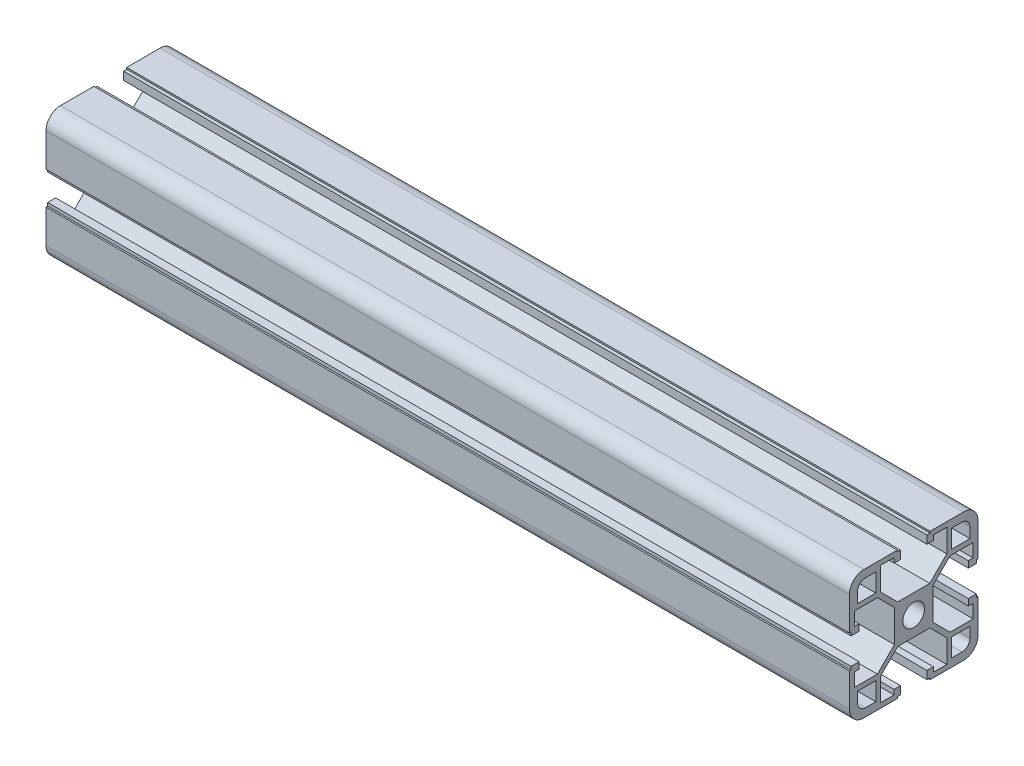
from build123d import *

# Parameters (mm, degrees)
SKETCH1_R                 = 3.4
F_40_X_40L_X_R4_5_1_DEPTH = 250


with BuildPart() as part:
    # Sketch1 → 铝型材 40 X 40L X R4.5(1) (new body)
    with BuildSketch(Plane(origin=(-142.412451362, 0, 0), x_dir=(0, 0, -1), z_dir=(1, 0, 0))):
        with BuildLine():
            Line((-5.1, 20), (-5.1, 19.5))
            Line((-5.1, 19.5), (-4.1, 19.5))
            Line((-4.1, 19.5), (-4.1, 17))
            Line((-4.1, 17), (-6.1, 17))
            Line((-6.1, 17), (-6.1, 18.5))
            Line((-6.1, 18.5), (-10.3, 18.5))
            Line((-10.3, 18.5), (-10.3, 11.3))
            Line((-10.3, 11.3), (-5, 6))
            Line((-5, 6), (5, 6))
            Line((5, 6), (10.3, 11.3))
            Line((10.3, 11.3), (10.3, 18.5))
            Line((10.3, 18.5), (6.1, 18.5))
            Line((6.1, 18.5), (6.1, 17))
            Line((6.1, 17), (4.1, 17))
            Line((4.1, 17), (4.1, 19.5))
            Line((4.1, 19.5), (5.1, 19.5))
            Line((5.1, 19.5), (5.1, 20))
            Line((5.1, 20), (15.5, 20))
            ThreePointArc((15.5, 20), (18.681980515, 18.681980515), (20, 15.5))
            Line((20, 15.5), (20, 5.1))
            Line((20, 5.1), (19.5, 5.1))
            Line((19.5, 5.1), (19.5, 4.1))
            Line((19.5, 4.1), (17, 4.1))
            Line((17, 4.1), (17, 6.1))
            Line((17, 6.1), (18.5, 6.1))
            Line((18.5, 6.1), (18.5, 10.3))
            Line((18.5, 10.3), (11.3, 10.3))
            Line((11.3, 10.3), (6, 5))
            Line((6, 5), (6, -5))
            Line((6, -5), (11.3, -10.3))
            Line((11.3, -10.3), (18.5, -10.3))
            Line((18.5, -10.3), (18.5, -6.1))
            Line((18.5, -6.1), (17, -6.1))
            Line((17, -6.1), (17, -4.1))
            Line((17, -4.1), (19.5, -4.1))
            Line((19.5, -4.1), (19.5, -5.1))
            Line((19.5, -5.1), (20, -5.1))
            Line((20, -5.1), (20, -15.5))
            ThreePointArc((20, -15.5), (18.681980515, -18.681980515), (15.5, -20))
            Line((15.5, -20), (5.1, -20))
            Line((5.1, -20), (5.1, -19.5))
            Line((5.1, -19.5), (4.1, -19.5))
            Line((4.1, -19.5), (4.1, -17))
            Line((4.1, -17), (6.1, -17))
            Line((6.1, -17), (6.1, -18.5))
            Line((6.1, -18.5), (10.3, -18.5))
            Line((10.3, -18.5), (10.3, -11.3))
            Line((10.3, -11.3), (5, -6))
            Line((5, -6), (-5, -6))
            Line((-5, -6), (-10.3, -11.3))
            Line((-10.3, -11.3), (-10.3, -18.5))
            Line((-10.3, -18.5), (-6.1, -18.5))
            Line((-6.1, -18.5), (-6.1, -17))
            Line((-6.1, -17), (-4.1, -17))
            Line((-4.1, -17), (-4.1, -19.5))
            Line((-4.1, -19.5), (-5.1, -19.5))
            Line((-5.1, -19.5), (-5.1, -20))
            Line((-5.1, -20), (-15.5, -20))
            ThreePointArc((-15.5, -20), (-18.681980515, -18.681980515), (-20, -15.5))
            Line((-20, -15.5), (-20, -5.1))
            Line((-20, -5.1), (-19.5, -5.1))
            Line((-19.5, -5.1), (-19.5, -4.1))
            Line((-19.5, -4.1), (-17, -4.1))
            Line((-17, -4.1), (-17, -6.1))
            Line((-17, -6.1), (-18.5, -6.1))
            Line((-18.5, -6.1), (-18.5, -10.3))
            Line((-18.5, -10.3), (-11.3, -10.3))
            Line((-11.3, -10.3), (-6, -5))
            Line((-6, -5), (-6, 5))
            Line((-6, 5), (-11.3, 10.3))
            Line((-11.3, 10.3), (-18.5, 10.3))
            Line((-18.5, 10.3), (-18.5, 6.1))
            Line((-18.5, 6.1), (-17, 6.1))
            Line((-17, 6.1), (-17, 4.1))
            Line((-17, 4.1), (-19.5, 4.1))
            Line((-19.5, 4.1), (-19.5, 5.1))
            Line((-19.5, 5.1), (-20, 5.1))
            Line((-20, 5.1), (-20, 15.5))
            ThreePointArc((-20, 15.5), (-18.681980515, 18.681980515), (-15.5, 20))
            Line((-15.5, 20), (-5.1, 20))
        make_face()
        Circle(SKETCH1_R, mode=Mode.SUBTRACT)
        with BuildLine():
            Line((11.8, 17.5), (15, 17.5))
            ThreePointArc((15, 17.5), (16.767766953, 16.767766953), (17.5, 15))
            Line((17.5, 15), (17.5, 11.8))
            Line((17.5, 11.8), (11.8, 11.8))
            Line((11.8, 11.8), (11.8, 17.5))
        make_face(mode=Mode.SUBTRACT)
        with BuildLine():
            Line((-15, 17.5), (-11.8, 17.5))
            Line((-11.8, 17.5), (-11.8, 11.8))
            Line((-11.8, 11.8), (-17.5, 11.8))
            Line((-17.5, 11.8), (-17.5, 15))
            ThreePointArc((-17.5, 15), (-16.767766953, 16.767766953), (-15, 17.5))
        make_face(mode=Mode.SUBTRACT)
        with BuildLine():
            Line((-17.5, -11.8), (-11.8, -11.8))
            Line((-11.8, -11.8), (-11.8, -17.5))
            Line((-11.8, -17.5), (-15, -17.5))
            ThreePointArc((-15, -17.5), (-16.767766953, -16.767766953), (-17.5, -15))
            Line((-17.5, -15), (-17.5, -11.8))
        make_face(mode=Mode.SUBTRACT)
        with BuildLine():
            Line((11.8, -11.8), (17.5, -11.8))
            Line((17.5, -11.8), (17.5, -15))
            ThreePointArc((17.5, -15), (16.767766953, -16.767766953), (15, -17.5))
            Line((15, -17.5), (11.8, -17.5))
            Line((11.8, -17.5), (11.8, -11.8))
        make_face(mode=Mode.SUBTRACT)
    extrude(amount=F_40_X_40L_X_R4_5_1_DEPTH)


solid = part.part
